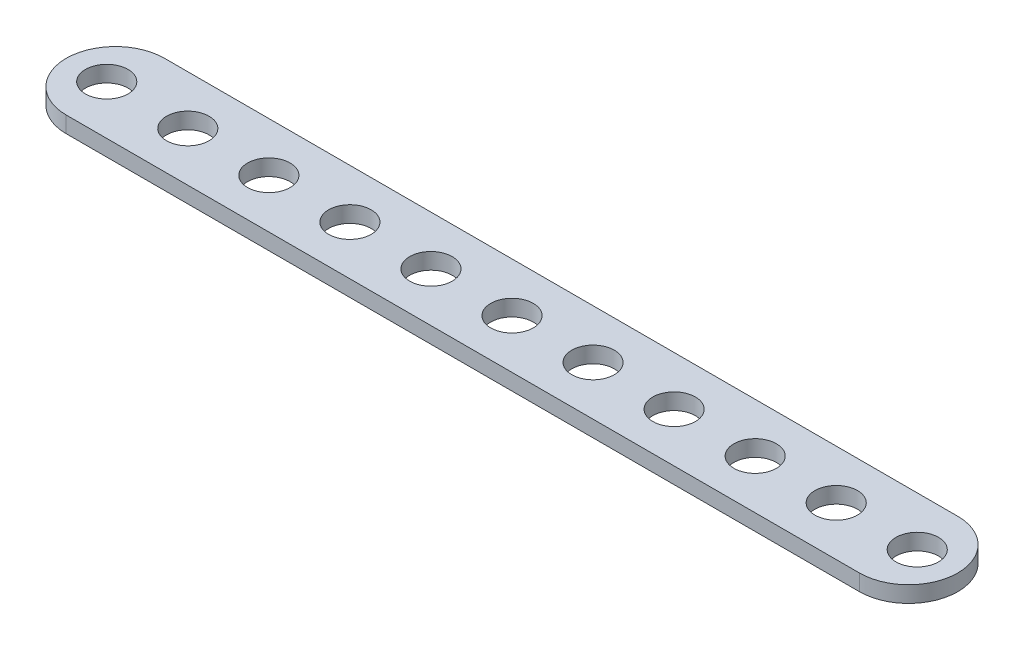
from build123d import *

# Parameters (mm, degrees)
BOSS_EXTRUDE1_DEPTH = 1.6
SKETCH2_R           = 2.1
CUT_EXTRUDE1_DEPTH  = 2.6
LPATTERN1_COUNT     = 11
LPATTERN1_PITCH     = 8


with BuildPart() as part:
    # Sketch1 → Boss-Extrude1 (new body)
    with BuildSketch(Plane(origin=(0, 0, 0), x_dir=(1, 0, 0), z_dir=(0, 1, 0))):
        with BuildLine():
            Line((4.85, 4.85), (83.15, 4.85))
            ThreePointArc((83.15, 4.85), (88, 0), (83.15, -4.85))
            Line((83.15, -4.85), (4.85, -4.85))
            ThreePointArc((4.85, -4.85), (0, 0), (4.85, 4.85))
        make_face()
    extrude(amount=BOSS_EXTRUDE1_DEPTH)

    # Sketch2 → Cut-Extrude1 (cut, through all)
    with BuildSketch(Plane(origin=(0, 1.6, 0), x_dir=(1, 0, 0), z_dir=(0, 1, 0))):
        with Locations((4, 0)):
            Circle(SKETCH2_R)
    cut_extrude1 = extrude(amount=-CUT_EXTRUDE1_DEPTH, mode=Mode.SUBTRACT)

    # LPattern1: Cut-Extrude1 ×11
    with Locations(*[(i * LPATTERN1_PITCH, 0, 0) for i in range(1, LPATTERN1_COUNT)]):
        add(cut_extrude1, mode=Mode.SUBTRACT)


solid = part.part
